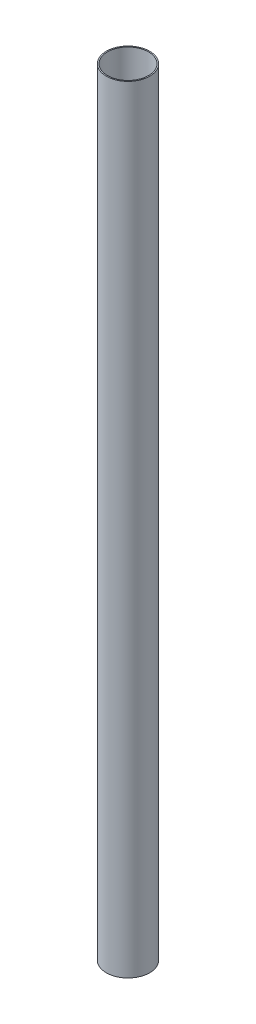
from build123d import *

# Parameters (mm, degrees)
SKETCH1_W = 1.524
SKETCH1_H = 1019.9878


with BuildPart() as part:
    # Sketch1 → Revolve1 (revolve)
    with BuildSketch(Plane.XY):
        with Locations((27.7368, 509.9939)):
            Rectangle(SKETCH1_W, SKETCH1_H)
    revolve(axis=Axis((0, 1146.81, 0), (0, -1, 0)))


solid = part.part
